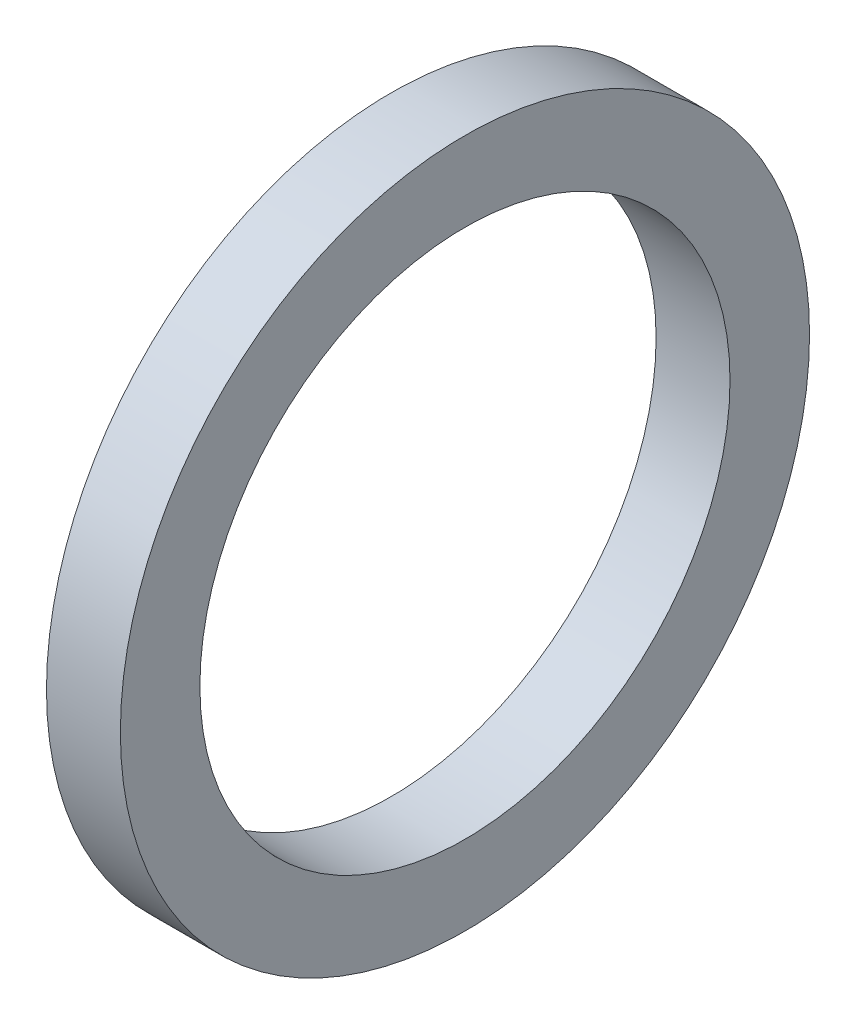
from build123d import *

# Parameters (mm, degrees)
SKETCH3_W = 6.97000003
SKETCH3_H = 7.499999986


with BuildPart() as part:
    # Sketch3 → Revolve1 (revolve)
    with BuildSketch(Plane.XY):
        with Locations((31.324800063, 28.750000031)):
            Rectangle(SKETCH3_W, SKETCH3_H)
    revolve(axis=Axis((0, 0, 0), (1, 0, 0)))


solid = part.part
